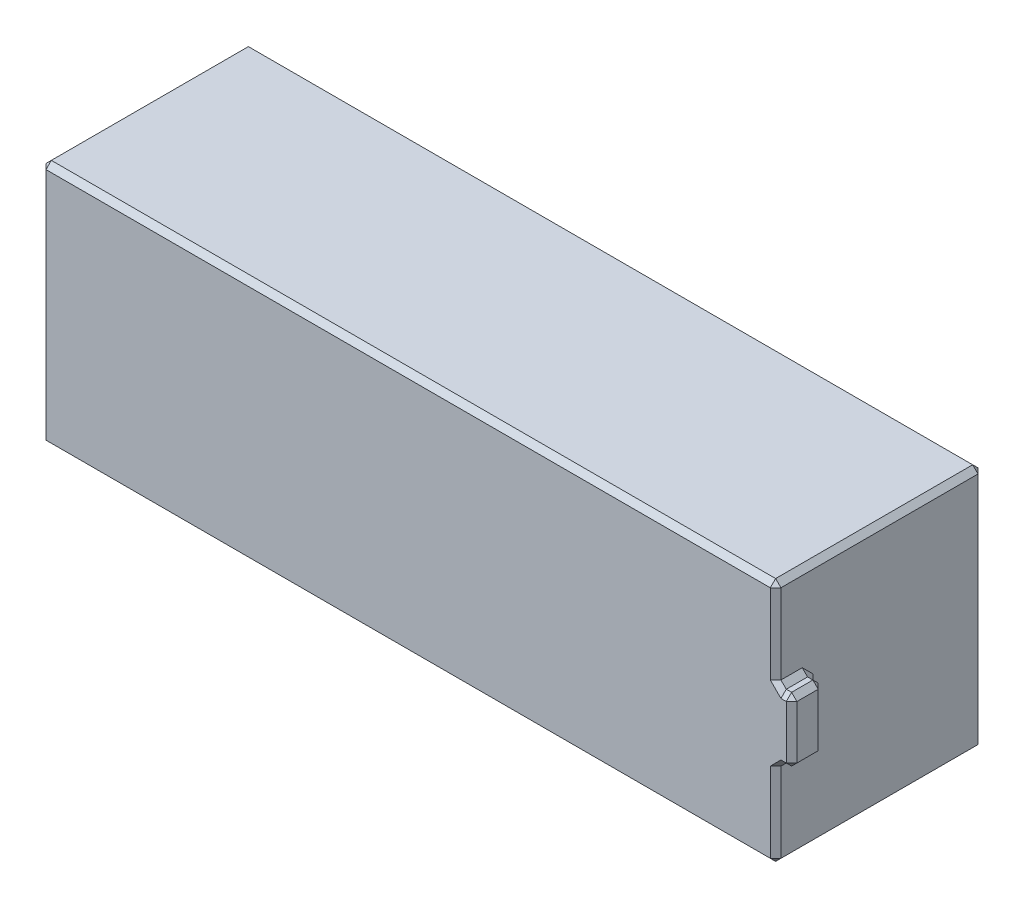
from build123d import *

# Parameters (mm, degrees)
SKETCH1_W           = 138
SKETCH1_H           = 46
BOSS_EXTRUDE1_DEPTH = 19.5
SKETCH2_W           = 6
SKETCH2_H           = 12
BOSS_EXTRUDE2_DEPTH = 3
CHAMFER1_SIZE       = 1


with BuildPart() as part:
    # Sketch1 → Boss-Extrude1 (new body, symmetric)
    with BuildSketch(Plane.XY):
        Rectangle(SKETCH1_W, SKETCH1_H)
    extrude(amount=BOSS_EXTRUDE1_DEPTH, both=True)

    # Sketch2 → Boss-Extrude2 (add, symmetric)
    with BuildSketch(Plane(origin=(69, 0, 0), x_dir=(0, 0, -1), z_dir=(1, 0, 0))):
        with Locations((-16.5, 0)):
            Rectangle(SKETCH2_W, SKETCH2_H)
    extrude(amount=BOSS_EXTRUDE2_DEPTH, both=True)

    # Chamfer1
    chamfer1_edges = [part.edges().sort_by_distance(p)[0] for p in [
        (-69, 0, 19.5),
        (0, -23, 19.5),
        (69, 14.5, 19.5),
        (69, 0, 13.5),
        (70.5, 6, 19.5),
        (70.5, -6, 13.5),
        (70.5, -6, 19.5),
        (69, -6, 16.5),
        (70.5, 6, 13.5),
        (69, 6, 16.5),
        (72, 0, 19.5),
        (72, -6, 16.5),
        (72, 0, 13.5),
        (72, 6, 16.5),
        (69, -14.5, 19.5),
        (0, -23, -19.5),
        (-69, 0, -19.5),
        (0, 23, -19.5),
        (69, 0, -19.5),
        (69, -23, 0),
        (-69, -23, 0),
        (-69, 23, 0),
        (69, 23, 0),
        (0, 23, 19.5),
    ]]
    chamfer(chamfer1_edges, length=CHAMFER1_SIZE)


solid = part.part
